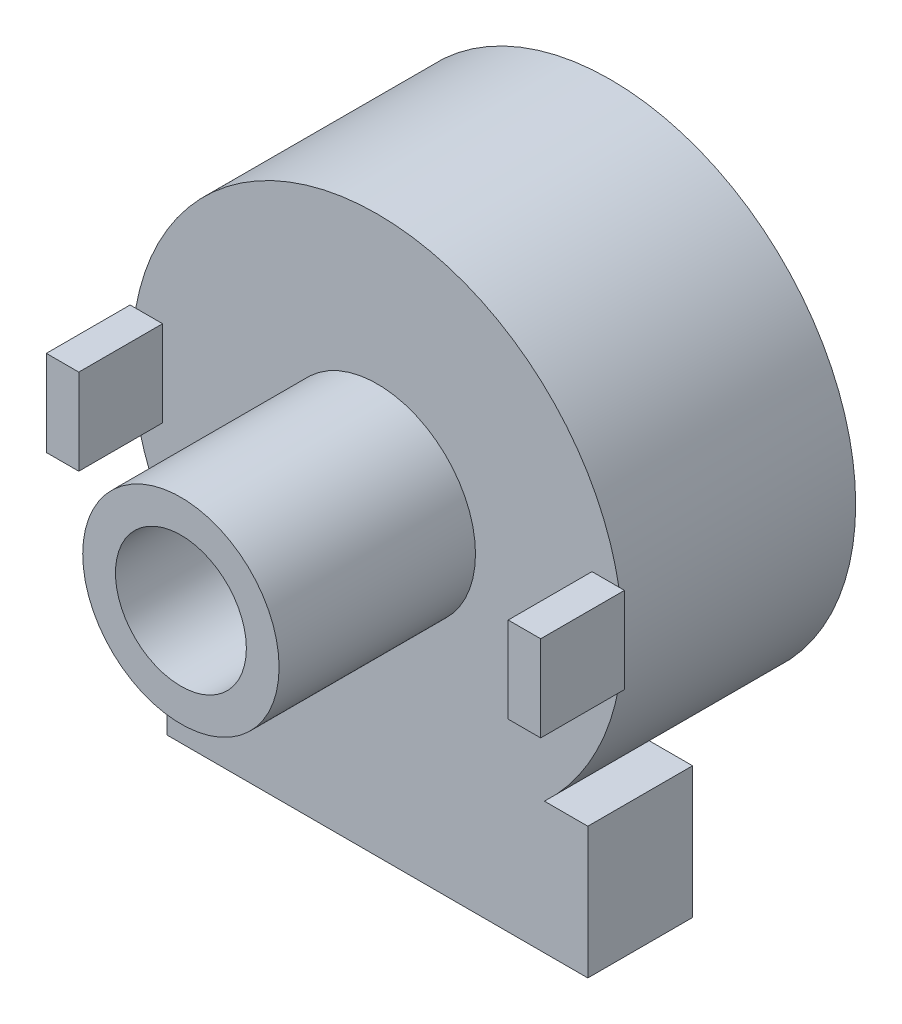
from build123d import *

# Parameters (mm, degrees)
SKETCH1_R          = 11.8999
BODY_DEPTH         = 11.303
SKETCH2_R          = 4.7625
BUSHING_DEPTH      = 9.525
SKETCH3_W          = 1.5748
SKETCH3_H          = 4.1656
MOUNT_TAB_DEPTH    = 4.064
SKETCH4_R          = 3.175
CUT_EXTRUDE1_DEPTH = 9.525
SKETCH5_W          = 20.4216
SKETCH5_H          = 6.3754
BOARD_DEPTH        = 5.08


with BuildPart() as part:
    # Sketch1 → Body (new body)
    with BuildSketch(Plane.XY):
        Circle(SKETCH1_R)
    extrude(amount=-BODY_DEPTH)

    # Sketch2 → bushing (add)
    with BuildSketch(Plane.XY):
        Circle(SKETCH2_R)
    extrude(amount=BUSHING_DEPTH)

    # Sketch3 → mount tab (add)
    with BuildSketch(Plane.XY):
        with Locations((-11.2014, 0)):
            Rectangle(SKETCH3_W, SKETCH3_H)
        with Locations((11.2014, 0)):
            Rectangle(SKETCH3_W, SKETCH3_H)
    extrude(amount=MOUNT_TAB_DEPTH)

    # Sketch4 → Cut-Extrude1 (cut)
    with BuildSketch(Plane.XY.offset(9.525)):
        Circle(SKETCH4_R)
    extrude(amount=-CUT_EXTRUDE1_DEPTH, mode=Mode.SUBTRACT)

    # Sketch5 → board (add)
    with BuildSketch(Plane.XY):
        with Locations((0, -11.8999)):
            Rectangle(SKETCH5_W, SKETCH5_H)
    extrude(amount=-BOARD_DEPTH)


solid = part.part
